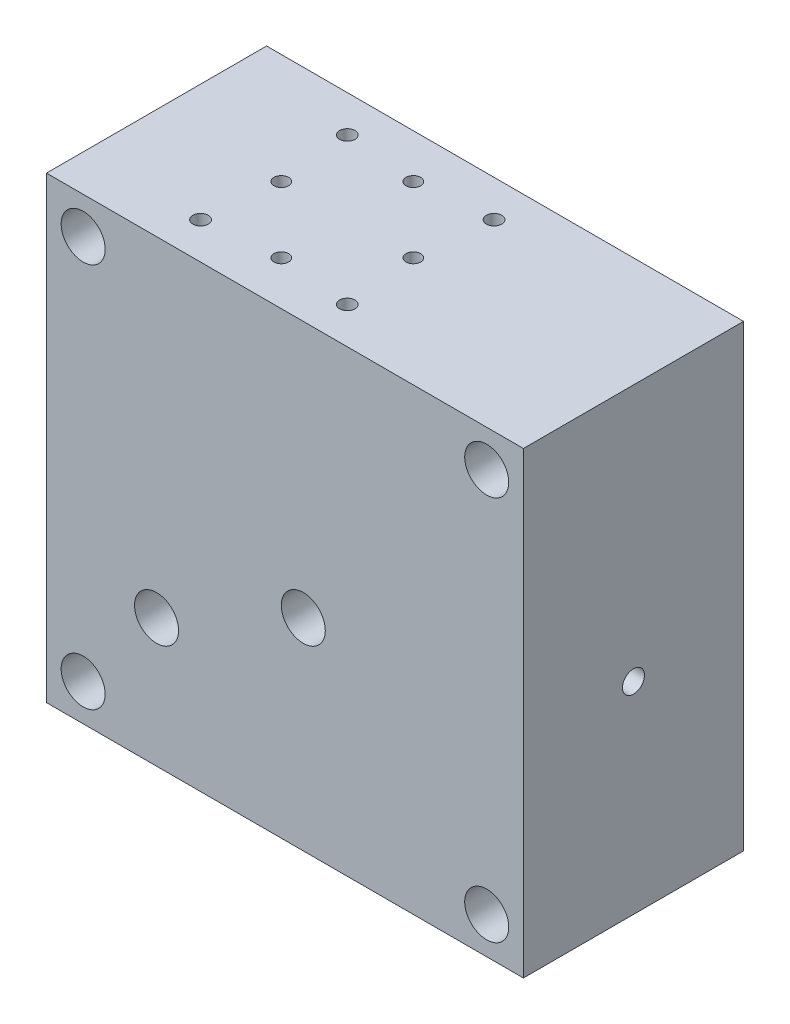
from build123d import *

# Parameters (mm, degrees)
SKETCH_1_W                  = 130
SKETCH_1_H                  = 125
SKETCH_1_R                  = 6
EXTRUDE_1_DEPTH             = 60
HOLE_WIZARD_12_0_12_1_D     = 12
HOLE_WIZARD_12_0_12_1_DEPTH = 30
HOLE_WIZARD_12_0_12_1_TIP   = 3.605163714
HOLE_WIZARD_12_0_12_2_D     = 12
HOLE_WIZARD_12_0_12_2_DEPTH = 12
HOLE_WIZARD_12_0_12_2_TIP   = 3.605163714
HOLE_WIZARD_4_0_4_1_D       = 4
HOLE_WIZARD_M10_2_D         = 8.5
HOLE_WIZARD_M10_2_DEPTH     = 14
HOLE_WIZARD_M10_2_TIP       = 2.553657631
HOLE_WIZARD_M5_2_D          = 4.2
HOLE_WIZARD_M5_2_DEPTH      = 14
HOLE_WIZARD_M5_2_TIP        = 1.2618073
HOLE_WIZARD_8_0_8_2_D       = 8
HOLE_WIZARD_8_0_8_2_DEPTH   = 52
HOLE_WIZARD_8_0_8_2_TIP     = 2.403442476
HOLE_WIZARD_M10_3_D         = 8.5
HOLE_WIZARD_M10_3_DEPTH     = 8
HOLE_WIZARD_M10_3_TIP       = 2.553657631
HOLE_WIZARD_8_0_8_3_D       = 8
HOLE_WIZARD_8_0_8_3_DEPTH   = 86
HOLE_WIZARD_8_0_8_3_TIP     = 2.403442476
SKETCH_3_R                  = 2
CUT_EXTRUDE_1_DEPTH         = 39
SKETCH_31_R                 = 3
CUT_EXTRUDE_2_DEPTH         = 60
SKETCH_32_R                 = 2
CUT_EXTRUDE_3_DEPTH         = 69
HOLE_WIZARD_M10_4_D         = 8.5
HOLE_WIZARD_M10_4_DEPTH     = 13.5
HOLE_WIZARD_M10_4_TIP       = 2.553657631


with BuildPart() as part:
    # 草图1 → 凸台-拉伸1 (new body)
    with BuildSketch(Plane.XY):
        Rectangle(SKETCH_1_W, SKETCH_1_H)
        with Locations((-55, -52.5)):
            Circle(SKETCH_1_R, mode=Mode.SUBTRACT)
        with Locations((55, -52.5)):
            Circle(SKETCH_1_R, mode=Mode.SUBTRACT)
        with Locations((55, 52.5)):
            Circle(SKETCH_1_R, mode=Mode.SUBTRACT)
        with Locations((-55, 52.5)):
            Circle(SKETCH_1_R, mode=Mode.SUBTRACT)
    extrude(amount=-EXTRUDE_1_DEPTH)

    # Ø12.0 (12) 直径孔1
    with Locations(Plane(origin=(5, -7.5, 0), x_dir=(1, 0, 0), z_dir=(0, 0, 1))):
        with Locations((0, 0)):
            Hole(HOLE_WIZARD_12_0_12_1_D / 2, depth=HOLE_WIZARD_12_0_12_1_DEPTH)
            with Locations((0, 0, -(HOLE_WIZARD_12_0_12_1_DEPTH + HOLE_WIZARD_12_0_12_1_TIP / 2))):  # 118° drill point
                Cone(0, HOLE_WIZARD_12_0_12_1_D / 2, HOLE_WIZARD_12_0_12_1_TIP, mode=Mode.SUBTRACT)

    # Ø12.0 (12) 直径孔2
    with Locations(Plane(origin=(-35, -27.5, 0), x_dir=(1, 0, 0), z_dir=(0, 0, 1))):
        with Locations((0, 0)):
            Hole(HOLE_WIZARD_12_0_12_2_D / 2, depth=HOLE_WIZARD_12_0_12_2_DEPTH)
            with Locations((0, 0, -(HOLE_WIZARD_12_0_12_2_DEPTH + HOLE_WIZARD_12_0_12_2_TIP / 2))):  # 118° drill point
                Cone(0, HOLE_WIZARD_12_0_12_2_D / 2, HOLE_WIZARD_12_0_12_2_TIP, mode=Mode.SUBTRACT)

    # Ø4.0 (4) 直径孔1 (through all)
    with Locations(Plane(origin=(0, 62.5, 0), x_dir=(1, 0, 0), z_dir=(0, 1, 0))):
        with Locations((-13, 48), (-31, 30)):
            Hole(HOLE_WIZARD_4_0_4_1_D / 2)

    # M10 螺纹孔2
    with Locations(Plane(origin=(0, -62.5, 0), x_dir=(-1, 0, 0), z_dir=(0, -1, 0))):
        with Locations((31, 30), (13, 48)):
            Hole(HOLE_WIZARD_M10_2_D / 2, depth=HOLE_WIZARD_M10_2_DEPTH)
            with Locations((0, 0, -(HOLE_WIZARD_M10_2_DEPTH + HOLE_WIZARD_M10_2_TIP / 2))):  # 118° drill point
                Cone(0, HOLE_WIZARD_M10_2_D / 2, HOLE_WIZARD_M10_2_TIP, mode=Mode.SUBTRACT)

    # M5 螺纹孔2
    with Locations(Plane(origin=(0, 62.5, 0), x_dir=(1, 0, 0), z_dir=(0, 1, 0))):
        with Locations((-33, 50), (7, 50), (7, 10), (-33, 10)):
            Hole(HOLE_WIZARD_M5_2_D / 2, depth=HOLE_WIZARD_M5_2_DEPTH)
            with Locations((0, 0, -(HOLE_WIZARD_M5_2_DEPTH + HOLE_WIZARD_M5_2_TIP / 2))):  # 118° drill point
                Cone(0, HOLE_WIZARD_M5_2_D / 2, HOLE_WIZARD_M5_2_TIP, mode=Mode.SUBTRACT)

    # Ø8.0 (8) 直径孔2
    with Locations(Plane(origin=(-65, 23.5, -12), x_dir=(0, 0, -1), z_dir=(-1, 0, 0))):
        with Locations((0, 0)):
            Hole(HOLE_WIZARD_8_0_8_2_D / 2, depth=HOLE_WIZARD_8_0_8_2_DEPTH)
            with Locations((0, 0, -(HOLE_WIZARD_8_0_8_2_DEPTH + HOLE_WIZARD_8_0_8_2_TIP / 2))):  # 118° drill point
                Cone(0, HOLE_WIZARD_8_0_8_2_D / 2, HOLE_WIZARD_8_0_8_2_TIP, mode=Mode.SUBTRACT)

    # M10 螺纹孔3
    with Locations(Plane(origin=(-65, 23.5, -12), x_dir=(0, 0, -1), z_dir=(-1, 0, 0))):
        with Locations((0, 0)):
            Hole(HOLE_WIZARD_M10_3_D / 2, depth=HOLE_WIZARD_M10_3_DEPTH)
            with Locations((0, 0, -(HOLE_WIZARD_M10_3_DEPTH + HOLE_WIZARD_M10_3_TIP / 2))):  # 118° drill point
                Cone(0, HOLE_WIZARD_M10_3_D / 2, HOLE_WIZARD_M10_3_TIP, mode=Mode.SUBTRACT)

    # Ø8.0 (8) 直径孔3
    with Locations(Plane(origin=(-35, -62.5, -12), x_dir=(0, 0, -1), z_dir=(0, -1, 0))):
        with Locations((0, 0)):
            Hole(HOLE_WIZARD_8_0_8_3_D / 2, depth=HOLE_WIZARD_8_0_8_3_DEPTH)
            with Locations((0, 0, -(HOLE_WIZARD_8_0_8_3_DEPTH + HOLE_WIZARD_8_0_8_3_TIP / 2))):  # 118° drill point
                Cone(0, HOLE_WIZARD_8_0_8_3_D / 2, HOLE_WIZARD_8_0_8_3_TIP, mode=Mode.SUBTRACT)

    # 草图3 → 切除-拉伸1 (cut)
    with BuildSketch(Plane(origin=(0, 62.5, 0), x_dir=(1, 0, 0), z_dir=(0, 1, 0))):
        with Locations((-13, 12)):
            Circle(SKETCH_3_R)
    extrude(amount=-CUT_EXTRUDE_1_DEPTH, mode=Mode.SUBTRACT)

    # 草图31 → 切除-拉伸2 (cut)
    with BuildSketch(Plane(origin=(65, 0, 0), x_dir=(0, 0, -1), z_dir=(1, 0, 0))):
        with Locations((30, -7.5)):
            Circle(SKETCH_31_R)
    extrude(amount=-CUT_EXTRUDE_2_DEPTH, mode=Mode.SUBTRACT)

    # 草图32 → 切除-拉伸3 (cut)
    with BuildSketch(Plane(origin=(0, 62.5, 0), x_dir=(1, 0, 0), z_dir=(0, 1, 0))):
        with Locations((5, 30)):
            Circle(SKETCH_32_R)
    extrude(amount=-CUT_EXTRUDE_3_DEPTH, mode=Mode.SUBTRACT)

    # M10 螺纹孔4
    with Locations(Plane(origin=(-35, -62.5, -12), x_dir=(0, 0, -1), z_dir=(0, -1, 0))):
        with Locations((0, 0)):
            Hole(HOLE_WIZARD_M10_4_D / 2, depth=HOLE_WIZARD_M10_4_DEPTH)
            with Locations((0, 0, -(HOLE_WIZARD_M10_4_DEPTH + HOLE_WIZARD_M10_4_TIP / 2))):  # 118° drill point
                Cone(0, HOLE_WIZARD_M10_4_D / 2, HOLE_WIZARD_M10_4_TIP, mode=Mode.SUBTRACT)


solid = part.part
